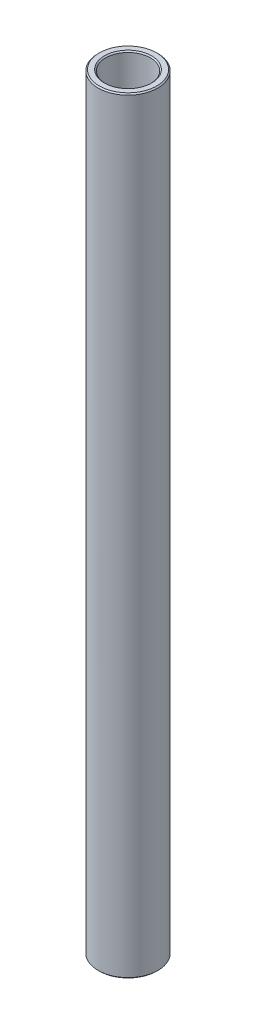
from build123d import *

# Parameters (mm, degrees)
SKETCH1_W     = 1.5875
SKETCH1_H     = 162.848779076
CHAMFER1_SIZE = 0.254


with BuildPart() as part:
    # Sketch1 → Revolve1 (revolve)
    with BuildSketch(Plane.XY):
        with Locations((5.55625, 213.186779468)):
            Rectangle(SKETCH1_W, SKETCH1_H)
    revolve(axis=Axis((0, 122.23738993, 0), (0, 1, 0)))

    # Chamfer1
    chamfer1_edges = [part.edges().sort_by_distance(p)[0] for p in [
        (-6.35, 131.76238993, 0),
        (-6.35, 294.611169006, 0),
        (-4.7625, 294.611169006, 0),
        (-4.7625, 131.76238993, 0),
    ]]
    chamfer(chamfer1_edges, length=CHAMFER1_SIZE)


solid = part.part
